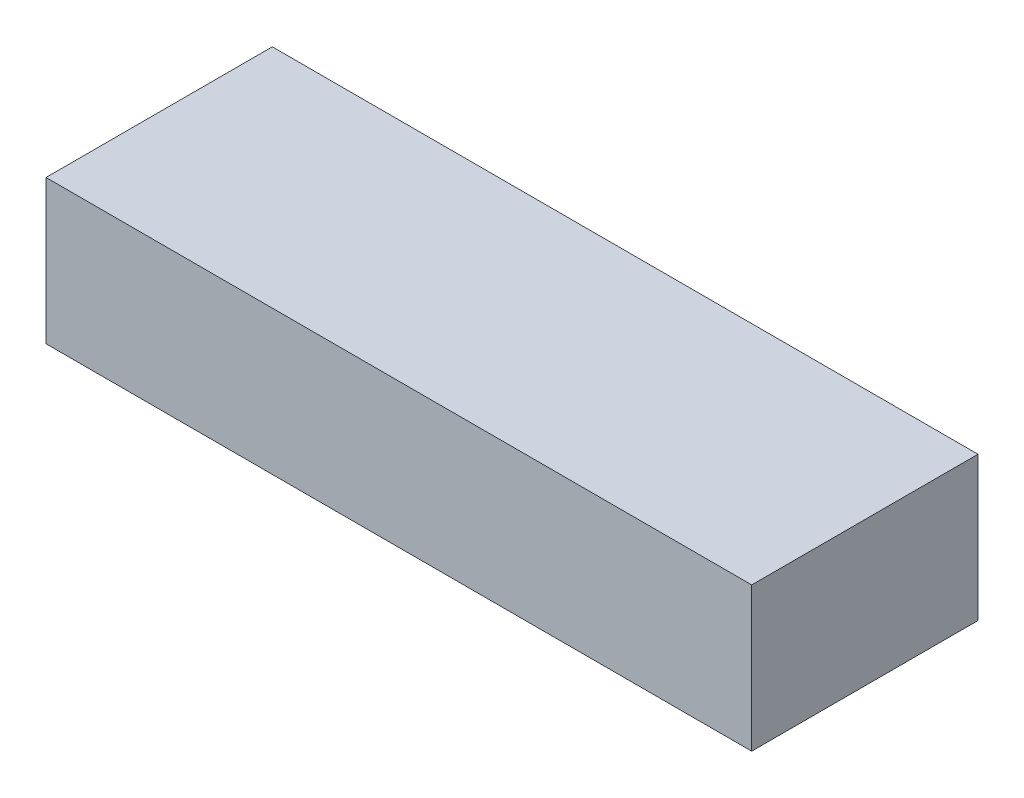
from build123d import *

# Parameters (mm, degrees)
SKETCH1_W           = 49
SKETCH1_H           = 15.71364
BOSS_EXTRUDE2_DEPTH = 10


with BuildPart() as part:
    # Sketch1 → Boss-Extrude2 (new body)
    with BuildSketch(Plane(origin=(0, 0, 0), x_dir=(1, 0, 0), z_dir=(0, 1, 0))):
        with Locations((-18.709090909, 7.85682)):
            Rectangle(SKETCH1_W, SKETCH1_H)
    extrude(amount=BOSS_EXTRUDE2_DEPTH)


solid = part.part
